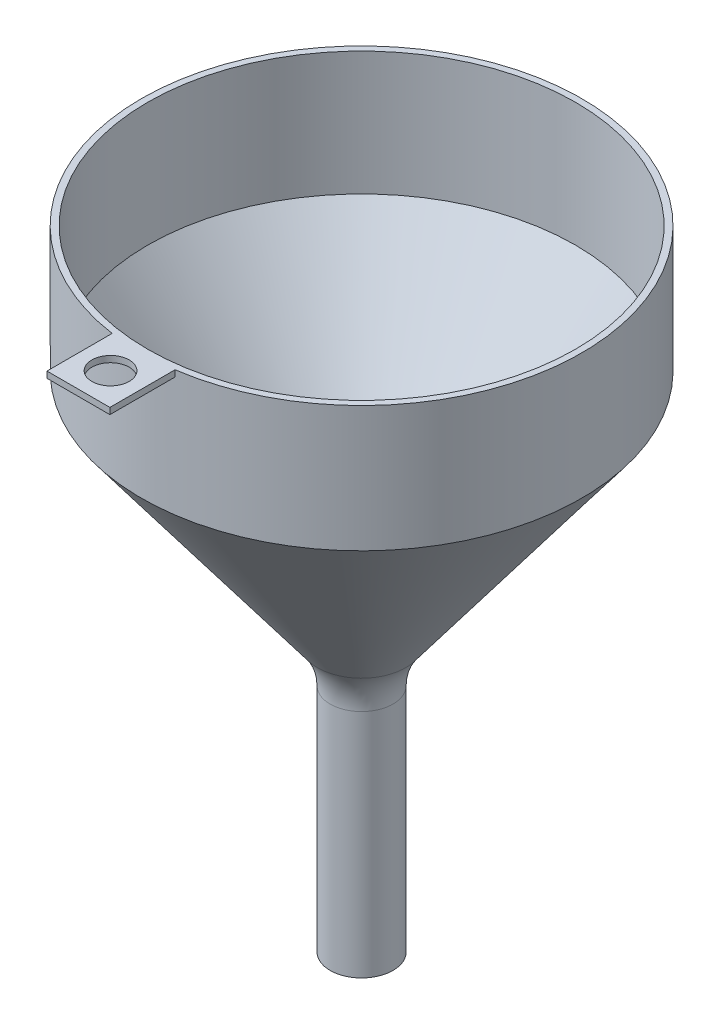
from build123d import *

# Parameters (mm, degrees)
VACIADO1_T              = -2
SALIENTE_EXTRUIR1_DEPTH = 2
CROQUIS3_R              = 5.931653108
CORTAR_EXTRUIR1_DEPTH   = 22
CROQUIS4_R              = 9.206232533
CORTAR_EXTRUIR2_DEPTH   = 82
REDONDEO1_R             = 20


with BuildPart() as part:
    # Croquis1 → Revolución1 (revolve)
    with BuildSketch(Plane.XY, mode=Mode.PRIVATE) as revoluci_n1_sk:
        Polygon((10, -20), (70, 60), (70, 100), (0, 100), (0, -100), (10, -100), align=None)
    revolve(revoluci_n1_sk.sketch.rotate(Axis((0, 100, 0), (0, -1, 0)), 180), axis=Axis((0, 100, 0), (0, -1, 0)))

    # Vaciado1
    vaciado1_openings = [part.faces().sort_by_distance(p)[0] for p in [
        (0, -100, 0),
        (0, 100, 0),
    ]]
    offset(amount=VACIADO1_T, openings=vaciado1_openings, kind=Kind.INTERSECTION)

    # Croquis2 → Saliente-Extruir1 (add)
    with BuildSketch(Plane(origin=(0, 100, 0), x_dir=(1, 0, 0), z_dir=(0, 1, 0))):
        with BuildLine():
            ThreePointArc((10, -69.282032303), (5.012870376, -69.82027736), (0, -70))
            Line((0, -70), (0, -90))
            Line((0, -90), (10, -90))
            Line((10, -90), (10, -69.282032303))
        make_face()
        with BuildLine():
            Line((0, -90), (0, -70))
            ThreePointArc((0, -70), (-5.012870376, -69.82027736), (-10, -69.282032303))
            Line((-10, -69.282032303), (-10, -90))
            Line((-10, -90), (0, -90))
        make_face()
    extrude(amount=-SALIENTE_EXTRUIR1_DEPTH)

    # Croquis3 → Cortar-Extruir1 (cut)
    with BuildSketch(Plane(origin=(0, 100, 0), x_dir=(1, 0, 0), z_dir=(0, 1, 0))):
        with Locations(Location((0, -79.795784901, 0), (0, 0, 180))):
            Circle(CROQUIS3_R)
    extrude(amount=-CORTAR_EXTRUIR1_DEPTH, mode=Mode.SUBTRACT)

    # Croquis4 → Cortar-Extruir2 (cut)
    with BuildSketch(Plane(origin=(0, -100, 0), x_dir=(-1, 0, 0), z_dir=(0, -1, 0))):
        with Locations(Location((0, 0, 0), (0, 0, 180))):
            Circle(CROQUIS4_R)
    extrude(amount=-CORTAR_EXTRUIR2_DEPTH, mode=Mode.SUBTRACT)

    # Redondeo1
    redondeo1_edges = [part.edges().sort_by_distance(p)[0] for p in [
        (10, -20, 0),
    ]]
    fillet(redondeo1_edges, radius=REDONDEO1_R)


solid = part.part
